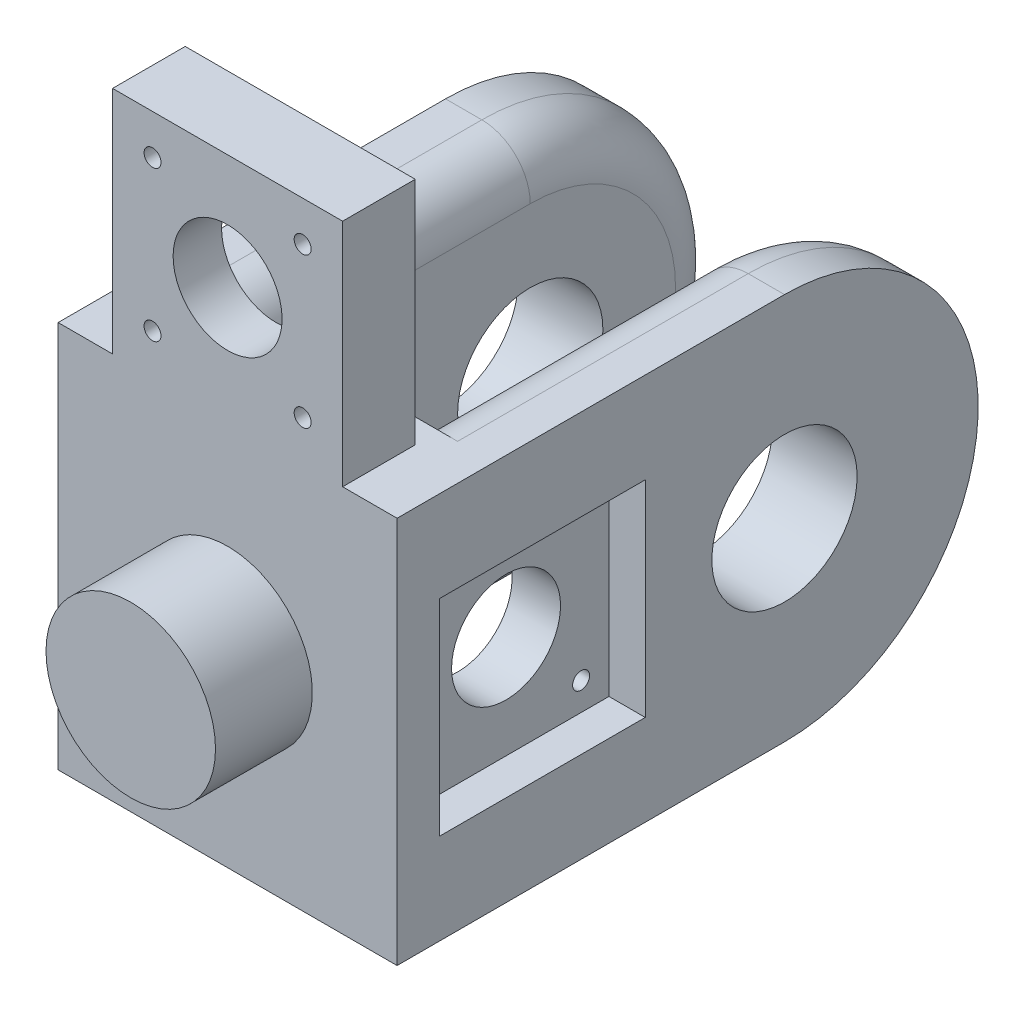
from build123d import *

# Parameters (mm, degrees)
SKETCH1_W               = 17.5
SKETCH1_H               = 80
BOSS_EXTRUDE1_DEPTH     = 100
BOSS_EXTRUDE1_2_DEPTH   = 100
SKETCH2_W               = 70
SKETCH2_H               = 80
BOSS_EXTRUDE2_DEPTH     = 20
CUT_EXTRUDE1_DEPTH      = 145.568322948
CUT_EXTRUDE1_DEPTH_BACK = 145.568322948
SKETCH5_R               = 11.25
CUT_EXTRUDE2_DEPTH      = 145.568322948
CUT_EXTRUDE2_DEPTH_BACK = 145.568322948
SKETCH6_W               = 42.5
SKETCH6_H               = 42.5
CUT_EXTRUDE3_DEPTH      = 7.5
SKETCH7_R               = 1.75
CUT_EXTRUDE4_DEPTH      = 145.568322948
CUT_EXTRUDE4_DEPTH_BACK = 145.568322948
SKETCH8_W               = 42.5
SKETCH8_H               = 42.5
CUT_EXTRUDE5_DEPTH      = 7.5
CUT_EXTRUDE7_DEPTH      = 35
SKETCH10_W              = 47.5
SKETCH10_H              = 15
BOSS_EXTRUDE3_DEPTH     = 47.5
SKETCH11_R              = 11.25
SKETCH11_R_2            = 1.75
CUT_EXTRUDE8_DEPTH      = 142.089510595
SKETCH12_W              = 42.5
SKETCH12_H              = 42.5
CUT_EXTRUDE9_DEPTH      = 5
SKETCH13_R              = 17.5
BOSS_EXTRUDE4_DEPTH     = 20
FILLET1_R               = 10


with BuildPart() as part:
    # Sketch1 → Boss-Extrude1 (new body)
    with BuildSketch(Plane.XY):
        with Locations((-26.25, 0)):
            Rectangle(SKETCH1_W, SKETCH1_H)
    extrude(amount=BOSS_EXTRUDE1_DEPTH)



with BuildPart() as body_2:
    # Sketch1 → Boss-Extrude1 2 (new body)
    with BuildSketch(Plane.XY):
        with Locations((26.25, 0)):
            Rectangle(SKETCH1_W, SKETCH1_H)
    extrude(amount=BOSS_EXTRUDE1_2_DEPTH)


with BuildPart() as part_1:
    add(part.part)

    add(body_2.part)  # Boss-Extrude2 merges body 2
    # Sketch2 → Boss-Extrude2 (add)
    with BuildSketch(Plane.XY.offset(100)):
        Rectangle(SKETCH2_W, SKETCH2_H)
    extrude(amount=BOSS_EXTRUDE2_DEPTH)

    # Sketch3 → Cut-Extrude1 (cut, two sides)
    with BuildSketch(Plane(origin=(35, 0, 0), x_dir=(0, 0, -1), z_dir=(1, 0, 0))) as cut_extrude1_sk:
        with BuildLine():
            ThreePointArc((-55, 0), (-40, -15), (-25, 0))
            Line((-25, 0), (-55, 0))
        make_face()
        with BuildLine():
            Line((-55, 0), (-25, 0))
            ThreePointArc((-25, 0), (-40, 15), (-55, 0))
        make_face()
        with BuildLine():
            ThreePointArc((-40, 40), (-11.715728753, 28.284271247), (0, 0))
            Line((0, 0), (0, 40))
            Line((0, 40), (-40, 40))
        make_face()
        with BuildLine():
            Line((0, -40), (0, 0))
            ThreePointArc((0, 0), (-11.715728753, -28.284271247), (-40, -40))
            Line((-40, -40), (0, -40))
        make_face()
    extrude(amount=CUT_EXTRUDE1_DEPTH, mode=Mode.SUBTRACT)
    extrude(cut_extrude1_sk.sketch, amount=-CUT_EXTRUDE1_DEPTH_BACK, mode=Mode.SUBTRACT)

    # Sketch5 → Cut-Extrude2 (cut, two sides)
    with BuildSketch(Plane.ZY.offset(35)) as cut_extrude2_sk:
        with Locations(Location((90, 0, 0), (0, 0, 270))):
            Circle(SKETCH5_R)
    extrude(amount=CUT_EXTRUDE2_DEPTH, mode=Mode.SUBTRACT)
    extrude(cut_extrude2_sk.sketch, amount=-CUT_EXTRUDE2_DEPTH_BACK, mode=Mode.SUBTRACT)

    # Sketch6 → Cut-Extrude3 (cut)
    with BuildSketch(Plane(origin=(35, 0, 0), x_dir=(0, 0, -1), z_dir=(1, 0, 0))):
        with Locations((-90, 0)):
            Rectangle(SKETCH6_W, SKETCH6_H)
    extrude(amount=-CUT_EXTRUDE3_DEPTH, mode=Mode.SUBTRACT)

    # Sketch7 → Cut-Extrude4 (cut, two sides)
    with BuildSketch(Plane(origin=(35, 0, 0), x_dir=(0, 0, -1), z_dir=(1, 0, 0))) as cut_extrude4_sk:
        with Locations((-105.5, 15.5)):
            Circle(SKETCH7_R)
        with Locations((-74.5, 15.5)):
            Circle(SKETCH7_R)
        with Locations((-74.5, -15.5)):
            Circle(SKETCH7_R)
        with Locations((-105.5, -15.5)):
            Circle(SKETCH7_R)
    extrude(amount=CUT_EXTRUDE4_DEPTH, mode=Mode.SUBTRACT)
    extrude(cut_extrude4_sk.sketch, amount=-CUT_EXTRUDE4_DEPTH_BACK, mode=Mode.SUBTRACT)

    # Sketch8 → Cut-Extrude5 (cut)
    with BuildSketch(Plane.ZY.offset(35)):
        with Locations((90, 0)):
            Rectangle(SKETCH8_W, SKETCH8_H)
    extrude(amount=-CUT_EXTRUDE5_DEPTH, mode=Mode.SUBTRACT)

    # Sketch9 → Cut-Extrude7 (cut)
    with BuildSketch(Plane.ZY.offset(-17.5)):
        with BuildLine():
            Line((105.5, 19.25), (95.963116285, 19.25))
            Line((95.963116285, 19.25), (95.963116285, 11.75))
            Line((95.963116285, 11.75), (105.5, 11.75))
            ThreePointArc((105.5, 11.75), (109.25, 15.5), (105.5, 19.25))
        make_face()
        with BuildLine():
            Line((105.5, -11.75), (95.963116285, -11.75))
            Line((95.963116285, -11.75), (95.963116285, -19.25))
            Line((95.963116285, -19.25), (105.5, -19.25))
            ThreePointArc((105.5, -19.25), (109.25, -15.5), (105.5, -11.75))
        make_face()
    extrude(amount=CUT_EXTRUDE7_DEPTH, mode=Mode.SUBTRACT)

    # Sketch10 → Boss-Extrude3 (add)
    with BuildSketch(Plane(origin=(0, 40, 0), x_dir=(1, 0, 0), z_dir=(0, 1, 0))):
        with Locations((0, -112.5)):
            Rectangle(SKETCH10_W, SKETCH10_H)
    extrude(amount=BOSS_EXTRUDE3_DEPTH)

    # Sketch11 → Cut-Extrude8 (cut, through all)
    with BuildSketch(Plane(origin=(0, 0, 105), x_dir=(-1, 0, 0), z_dir=(0, 0, -1))):
        with Locations((0, 63.75)):
            Circle(SKETCH11_R)
        with Locations((15.5, 79.25)):
            Circle(SKETCH11_R_2)
        with Locations((15.5, 48.25)):
            Circle(SKETCH11_R_2)
        with Locations((-15.5, 48.25)):
            Circle(SKETCH11_R_2)
        with Locations((-15.5, 79.25)):
            Circle(SKETCH11_R_2)
    extrude(amount=-CUT_EXTRUDE8_DEPTH, mode=Mode.SUBTRACT)

    # Sketch12 → Cut-Extrude9 (cut)
    with BuildSketch(Plane(origin=(0, 0, 105), x_dir=(-1, 0, 0), z_dir=(0, 0, -1))):
        with Locations((0, 63.75)):
            Rectangle(SKETCH12_W, SKETCH12_H)
    extrude(amount=-CUT_EXTRUDE9_DEPTH, mode=Mode.SUBTRACT)

    # Sketch13 → Boss-Extrude4 (add)
    with BuildSketch(Plane.XY.offset(120)):
        with Locations(Location((0, 0, 0), (0, 0, 180))):
            Circle(SKETCH13_R)
    extrude(amount=BOSS_EXTRUDE4_DEPTH)

    # Fillet1
    fillet1_edges = [part_1.edges().sort_by_distance(p)[0] for p in [
        (-17.5, -40, 70),
        (-17.5, 40, 70),
        (17.5, 0, 0),
        (-17.5, 0, 0),
        (17.5, -40, 70),
        (17.5, 40, 70),
    ]]
    fillet(fillet1_edges, radius=FILLET1_R)


solid = part_1.part
